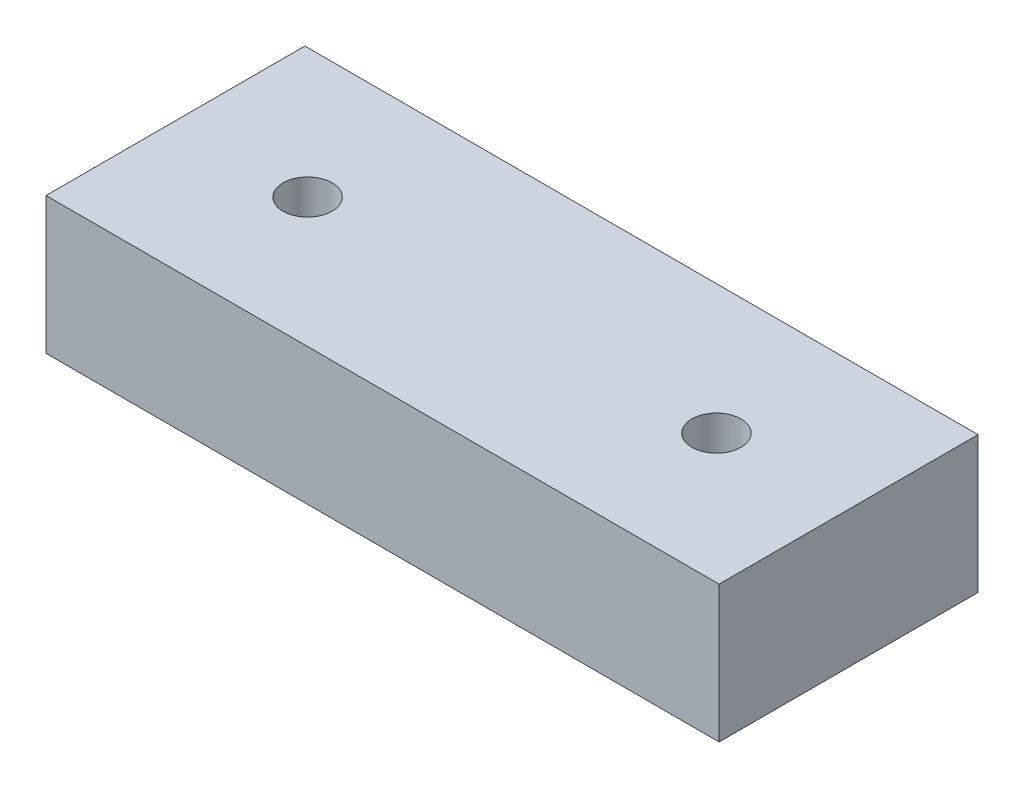
from build123d import *

# Parameters (mm, degrees)
SKETCH1_W                 = 30.95625
SKETCH1_H                 = 11.90625
BOSS_EXTRUDE1_DEPTH       = 6.2865
SKETCH2_R                 = 2.38125
CUT_EXTRUDE1_DEPTH        = 4.7625
F_4_40_TAPPED_HOLE1_D     = 2.2606
F_4_40_TAPPED_HOLE1_DEPTH = 8.89
F_4_40_TAPPED_HOLE1_TIP   = 0.679152758


with BuildPart() as part:
    # Sketch1 → Boss-Extrude1 (new body)
    with BuildSketch(Plane(origin=(0, 0, 0), x_dir=(1, 0, 0), z_dir=(0, 1, 0))):
        Rectangle(SKETCH1_W, SKETCH1_H)
    extrude(amount=BOSS_EXTRUDE1_DEPTH)

    # Sketch2 → Cut-Extrude1 (cut)
    with BuildSketch(Plane.XZ):
        Circle(SKETCH2_R)
    extrude(amount=-CUT_EXTRUDE1_DEPTH, mode=Mode.SUBTRACT)

    # #4-40 Tapped Hole1
    with Locations(Plane(origin=(0, 6.2865, 0), x_dir=(-1, 0, 0), z_dir=(0, 1, 0))):
        with Locations((9.402022244, 0), (-9.402022244, 0)):
            Hole(F_4_40_TAPPED_HOLE1_D / 2, depth=F_4_40_TAPPED_HOLE1_DEPTH)
            with Locations((0, 0, -(F_4_40_TAPPED_HOLE1_DEPTH + F_4_40_TAPPED_HOLE1_TIP / 2))):  # 118° drill point
                Cone(0, F_4_40_TAPPED_HOLE1_D / 2, F_4_40_TAPPED_HOLE1_TIP, mode=Mode.SUBTRACT)


solid = part.part
